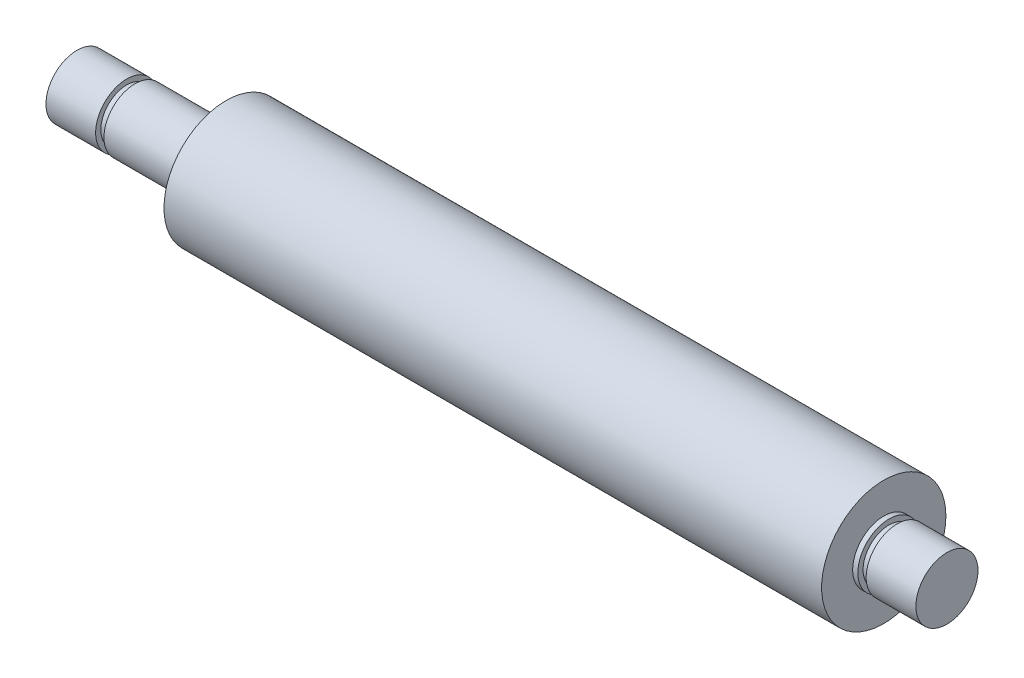
from build123d import *


with BuildPart() as part:
    # Sketch1 → Revolve1 (revolve)
    with BuildSketch(Plane.XY):
        Polygon((-42, 3), (-42, 0), (42, 0), (42, 3), (37.2, 3), (37.2, 2.5), (36.4, 2.5), (36.4, 3), (35.9, 3), (35.9, 6), (-27.6, 6), (-27.6, 3), (-36.4, 3), (-36.4, 2.5), (-37.2, 2.5), (-37.2, 3), align=None)
    revolve(axis=Axis((-42, 0, 0), (1, 0, 0)))


solid = part.part
